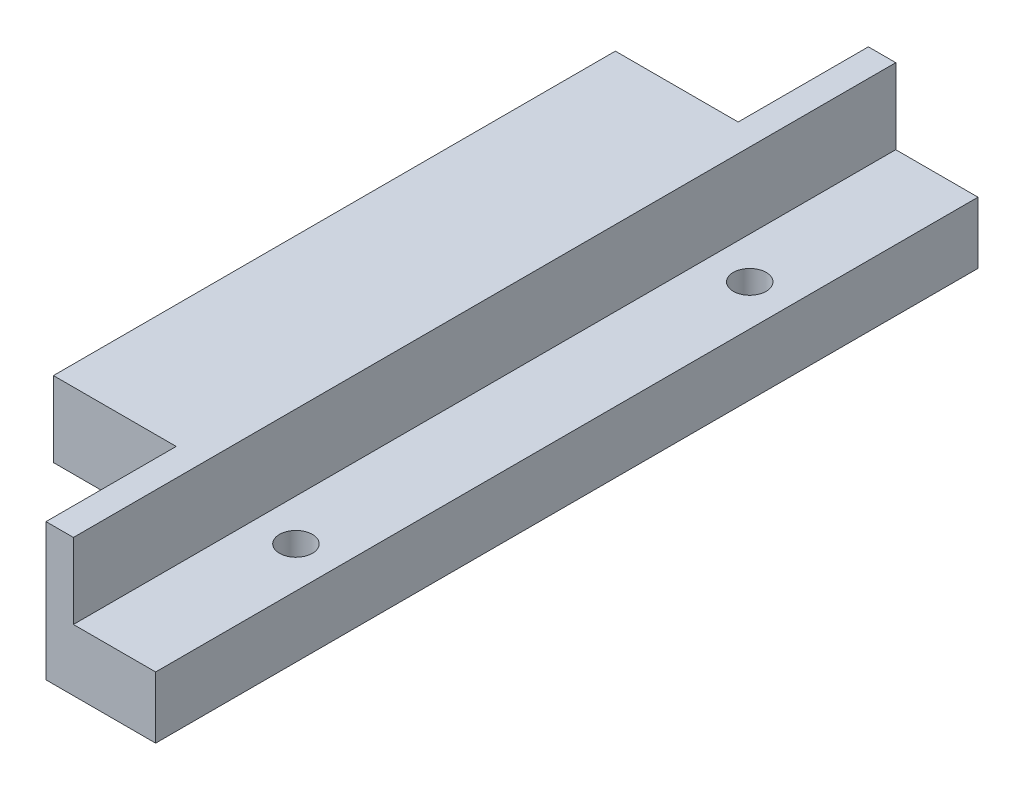
from build123d import *

# Parameters (mm, degrees)
SKETCH3_W            = 4.5
SKETCH3_H            = 48
SKETCH3_W_2          = 8
SKETCH3_H_2          = 60
BOSS_EXTRUDE2_DEPTH  = 4.5
SKETCH4_W            = 5
SKETCH4_H            = 41
BOSS_EXTRUDE3_DEPTH  = 5.5
SKETCH6_W            = 2
SKETCH6_H            = 60
BOSS_EXTRUDE4_DEPTH  = 5.5
SKETCH7_W            = 41
SKETCH7_H            = 5.5
BOSS_EXTRUDE5_DEPTH  = 4
M2_CLEARANCE_SLOT1_D = 2.4


with BuildPart() as part:
    # Sketch3 → Boss-Extrude2 (new body)
    with BuildSketch(Plane(origin=(0, 0, 0), x_dir=(1, 0, 0), z_dir=(0, 1, 0))):
        with Locations((-8.027777778, 26.190445059)):
            Rectangle(SKETCH3_W, SKETCH3_H)
        with Locations((-1.777777778, 26.190445059)):
            Rectangle(SKETCH3_W_2, SKETCH3_H_2)
    extrude(amount=BOSS_EXTRUDE2_DEPTH)

    # Sketch4 → Boss-Extrude3 (add)
    with BuildSketch(Plane(origin=(0, 4.5, 0), x_dir=(1, 0, 0), z_dir=(0, 1, 0))):
        with Locations((-8.23478156, 26.190445059)):
            Rectangle(SKETCH4_W, SKETCH4_H)
    extrude(amount=BOSS_EXTRUDE3_DEPTH)

    # Sketch6 → Boss-Extrude4 (add)
    with BuildSketch(Plane(origin=(0, 4.5, 0), x_dir=(1, 0, 0), z_dir=(0, 1, 0))):
        with Locations((-4.777777778, 26.190445059)):
            Rectangle(SKETCH6_W, SKETCH6_H)
    extrude(amount=BOSS_EXTRUDE4_DEPTH)

    # Sketch7 → Boss-Extrude5 (add)
    with BuildSketch(Plane.ZY.offset(10.73478156)):
        with Locations((-26.190445059, 7.25)):
            Rectangle(SKETCH7_W, SKETCH7_H)
    extrude(amount=BOSS_EXTRUDE5_DEPTH)

    # M2 Clearance Slot1 (through all)
    with Locations(Plane(origin=(-24.675307519, 4.5, -134.803183417), x_dir=(1, 0, 0), z_dir=(0, 1, 0))):
        with Locations((23.920998694, -125.399645606), (23.920998694, -92.291639463)):
            Hole(M2_CLEARANCE_SLOT1_D / 2)


solid = part.part
